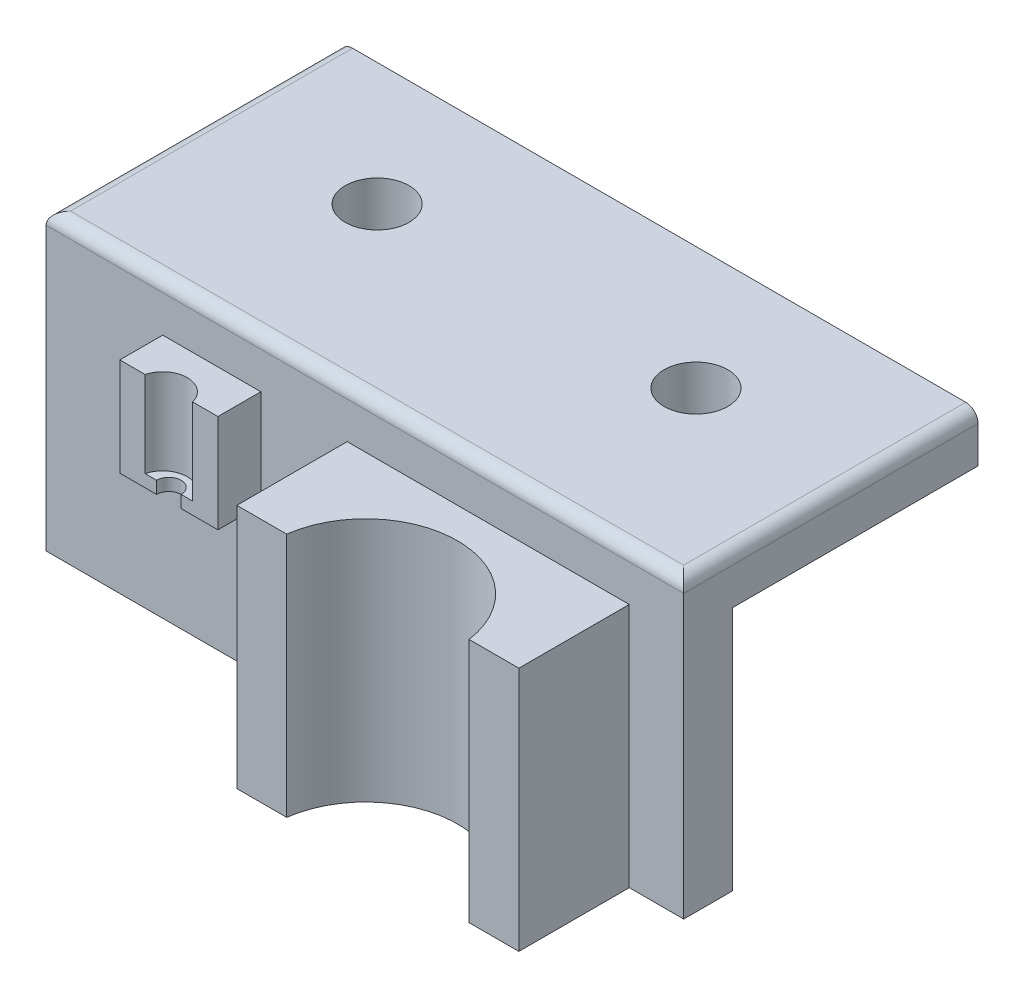
from build123d import *

# Parameters (mm, degrees)
SKETCH_1_W                = 40
SKETCH_1_H                = 40
EXTRUDE_1_DEPTH           = 4
SKETCH_2_W                = 40
SKETCH_2_H                = 4
EXTRUDE_2_DEPTH           = 4
SKETCH_3_W                = 40
SKETCH_3_H                = 4
EXTRUDE_3_DEPTH           = 20
SKETCH_4_W                = 8
SKETCH_4_H                = 12
EXTRUDE_4_DEPTH           = 4
CUT_EXTRUDE_1_DEPTH       = 11
EXTRUDE_5_DEPTH           = 4
EXTRUDE_6_DEPTH           = 4
EXTRUDE_7_DEPTH           = 4
SKETCH_10_W               = 23
SKETCH_10_H               = 24.293070416
EXTRUDE_8_DEPTH           = 10
CUT_EXTRUDE_3_DEPTH       = 25.293070415
SKETCH_14_W               = 8
SKETCH_14_H               = 0.5
CUT_EXTRUDE_4_DEPTH       = 45
SKETCH_15_W               = 23
SKETCH_15_H               = 1
CUT_EXTRUDE_5_DEPTH       = 45
SKETCH_16_R               = 2.6
CUT_EXTRUDE_6_DEPTH       = 7
SKETCH_17_W               = 52
SKETCH_17_H               = 4
CUT_EXTRUDE_7_DEPTH       = 20
CUT_EXTRUDE_8_DEPTH       = 0.29
SKETCH_20_R               = 1
CUT_EXTRUDE_9_DEPTH       = 11
CUT_EXTRUDE_10_DEPTH      = 1
CUT_EXTRUDE_10_DEPTH_BACK = 4
FILLET_1_R                = 1


with BuildPart() as part:
    # 草图1 → 凸台-拉伸1 (new body)
    with BuildSketch(Plane.XY):
        with Locations((-0.053475936, -8.663101604)):
            Rectangle(SKETCH_1_W, SKETCH_1_H)
    extrude(amount=EXTRUDE_1_DEPTH)

    # 草图2 → 凸台-拉伸2 (add)
    with BuildSketch(Plane(origin=(0, 11.336898396, 0), x_dir=(1, 0, 0), z_dir=(0, 1, 0))):
        with Locations((-0.053475936, -2)):
            Rectangle(SKETCH_2_W, SKETCH_2_H)
    extrude(amount=EXTRUDE_2_DEPTH)

    # 草图3 → 凸台-拉伸3 (add)
    with BuildSketch(Plane(origin=(0, 0, 0), x_dir=(-1, 0, 0), z_dir=(0, 0, -1))):
        with Locations((0.053475936, 13.336898396)):
            Rectangle(SKETCH_3_W, SKETCH_3_H)
    extrude(amount=EXTRUDE_3_DEPTH)

    # 草图4 → 凸台-拉伸4 (add)
    with BuildSketch(Plane.XY.offset(4)):
        with Locations((-10.534642548, 9.336898396)):
            Rectangle(SKETCH_4_W, SKETCH_4_H)
    extrude(amount=EXTRUDE_4_DEPTH)

    # 草图6 → 切除-拉伸1 (cut)
    with BuildSketch(Plane(origin=(0, 15.336898396, 0), x_dir=(1, 0, 0), z_dir=(0, 1, 0))):
        with BuildLine():
            Line((-8.534642548, -8), (-12.534642548, -8))
            ThreePointArc((-12.534642548, -8), (-10.534642548, -6), (-8.534642548, -8))
        make_face()
    extrude(amount=-CUT_EXTRUDE_1_DEPTH, mode=Mode.SUBTRACT)

    # 草图8 → 凸台-拉伸5 (add)
    with BuildSketch(Plane.ZY.offset(20.053475936)):
        Polygon((4, 15.336898396), (-20, 15.336898396), (-20, 11.336898396), (0, 11.336898396), (0, -28.663101604), (4, -28.663101604), align=None)
    extrude(amount=EXTRUDE_5_DEPTH)

    # 草图9 → 凸台-拉伸6 (add)
    with BuildSketch(Plane(origin=(19.946524064, 0, 0), x_dir=(0, 0, -1), z_dir=(1, 0, 0))):
        Polygon((0, -28.663101604), (0, 11.336898396), (20, 11.336898396), (20, 15.336898396), (-4, 15.336898396), (-4, -28.663101604), align=None)
    extrude(amount=EXTRUDE_6_DEPTH)

    # 草图11 → 凸台-拉伸7 (add)
    with BuildSketch(Plane(origin=(23.946524064, 0, 0), x_dir=(0, 0, -1), z_dir=(1, 0, 0))):
        Polygon((-4, -28.663101604), (0, -28.663101604), (0, 11.336898396), (20, 11.336898396), (20, 15.336898396), (-4, 15.336898396), align=None)
    extrude(amount=EXTRUDE_7_DEPTH)

    # 草图10 → 凸台-拉伸8 (add)
    with BuildSketch(Plane.XY.offset(4)):
        with Locations((12.007361252, 3.190363188)):
            Rectangle(SKETCH_10_W, SKETCH_10_H)
    extrude(amount=EXTRUDE_8_DEPTH)

    # 草图12 → 切除-拉伸3 (cut, through all)
    with BuildSketch(Plane.XZ.offset(8.95617202)):
        with BuildLine():
            Line((4.507361252, 14), (19.507361252, 14))
            ThreePointArc((19.507361252, 14), (12.007361252, 6.5), (4.507361252, 14))
        make_face()
    extrude(amount=-CUT_EXTRUDE_3_DEPTH, mode=Mode.SUBTRACT)

    # 草图14 → 切除-拉伸4 (cut, through all)
    with BuildSketch(Plane(origin=(0, 15.336898396, 0), x_dir=(1, 0, 0), z_dir=(0, 1, 0))):
        with Locations((-10.534642548, -7.75)):
            Rectangle(SKETCH_14_W, SKETCH_14_H)
    extrude(amount=-CUT_EXTRUDE_4_DEPTH, mode=Mode.SUBTRACT)

    # 草图15 → 切除-拉伸5 (cut, through all)
    with BuildSketch(Plane(origin=(0, 15.336898396, 0), x_dir=(1, 0, 0), z_dir=(0, 1, 0))):
        with Locations((12.007361252, -13.5)):
            Rectangle(SKETCH_15_W, SKETCH_15_H)
    extrude(amount=-CUT_EXTRUDE_5_DEPTH, mode=Mode.SUBTRACT)

    # 草图16 → 切除-拉伸6 (cut)
    with BuildSketch(Plane(origin=(0, 15.336898396, 0), x_dir=(1, 0, 0), z_dir=(0, 1, 0))):
        with Locations((-11.053475936, 10)):
            Circle(SKETCH_16_R)
        with Locations((14.946524064, 10)):
            Circle(SKETCH_16_R)
    extrude(amount=-CUT_EXTRUDE_6_DEPTH, mode=Mode.SUBTRACT)

    # 草图17 → 切除-拉伸7 (cut)
    with BuildSketch(Plane.XZ.offset(28.663101604)):
        with Locations((1.946524064, 2)):
            Rectangle(SKETCH_17_W, SKETCH_17_H)
    extrude(amount=-CUT_EXTRUDE_7_DEPTH, mode=Mode.SUBTRACT)

    # 草图19 → 切除-拉伸8 (cut)
    with BuildSketch(Plane.XZ.offset(8.95617202)):
        with BuildLine():
            Line((23.507361252, 4), (23.507361252, 13))
            Line((23.507361252, 13), (19.440395626, 13))
            ThreePointArc((19.440395626, 13), (12.007361252, 6.5), (4.574326878, 13))
            Line((4.574326878, 13), (0.507361252, 13))
            Line((0.507361252, 13), (0.507361252, 4))
            Line((0.507361252, 4), (23.507361252, 4))
        make_face()
    extrude(amount=-CUT_EXTRUDE_8_DEPTH, mode=Mode.SUBTRACT)

    # 草图20 → 切除-拉伸9 (cut)
    with BuildSketch(Plane(origin=(0, 3.336898396, 0), x_dir=(-1, 0, 0), z_dir=(0, -1, 0))):
        with Locations((10.534642548, -7.5)):
            Circle(SKETCH_20_R)
    extrude(amount=-CUT_EXTRUDE_9_DEPTH, mode=Mode.SUBTRACT)

    # 草图21 → 切除-拉伸10 (cut, two sides)
    with BuildSketch(Plane(origin=(0, 15.336898396, 0), x_dir=(1, 0, 0), z_dir=(0, 1, 0))) as cut_extrude_10_sk:
        Polygon((152.48909257, -4), (27.946524064, -4), (-24.053475936, -4), (-148.596044442, -4), (-148.596044442, -253.085137012), (152.48909257, -253.085137012), align=None)
    extrude(amount=CUT_EXTRUDE_10_DEPTH, mode=Mode.SUBTRACT)
    extrude(cut_extrude_10_sk.sketch, amount=-CUT_EXTRUDE_10_DEPTH_BACK, mode=Mode.SUBTRACT)

    # 圆角1
    fillet_1_edges = [part.edges().sort_by_distance(p)[0] for p in [
        (1.946524064, 15.336898396, 4),
        (-24.053475936, 15.336898396, -8),
        (27.946524064, 15.336898396, -8),
    ]]
    fillet(fillet_1_edges, radius=FILLET_1_R)


solid = part.part
